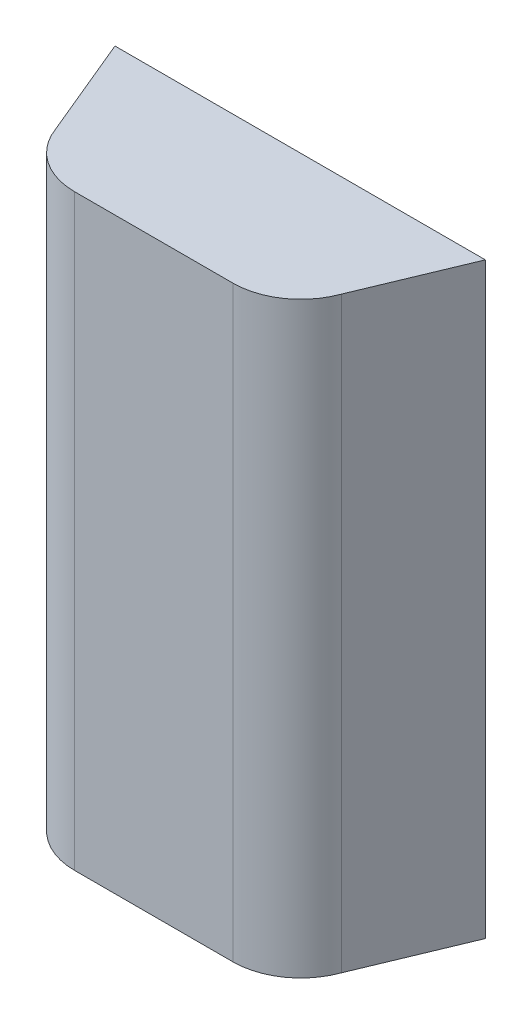
from build123d import *

# Parameters (mm, degrees)
BOSS_EXTRUDE1_DEPTH = 260
CUT_EXTRUDE1_DEPTH  = 256


with BuildPart() as part:
    # Sketch1 → Boss-Extrude1 (new body)
    with BuildSketch(Plane(origin=(0, 0, 0), x_dir=(1, 0, 0), z_dir=(0, 1, 0))):
        with BuildLine():
            Line((35, 0), (-35, 0))
            ThreePointArc((-35, 0), (-52.207293091, 5.425438671), (-63.190778624, 19.7393957))
            Line((-63.190778624, 19.7393957), (-81.908713693, 64.7393957))
            Line((-81.908713693, 64.7393957), (81.908713693, 64.7393957))
            Line((81.908713693, 64.7393957), (63.190778624, 19.7393957))
            ThreePointArc((63.190778624, 19.7393957), (52.207293091, 5.425438671), (35, 0))
        make_face()
    extrude(amount=BOSS_EXTRUDE1_DEPTH)

    # Sketch4 → Cut-Extrude1 (cut)
    with BuildSketch(Plane.XZ):
        with BuildLine():
            Line((-78.908713693, -64.7393957), (78.908713693, -64.7393957))
            Line((78.908713693, -64.7393957), (60.788869437, -21.764400459))
            add(Edge.make_bspline(
                [(35, -3), (54.769523096, -6.842262635), (60.788869437, -21.764400459)],
                knots=[0, 0, 0, 1, 1, 1], degree=2))
            Line((35, -3), (-35, -3))
            add(Edge.make_bspline(
                [(-35, -3), (-54.769523096, -6.842262635), (-60.788869437, -21.764400459)],
                knots=[0, 0, 0, 1, 1, 1], degree=2))
            Line((-60.788869437, -21.764400459), (-78.908713693, -64.7393957))
        make_face()
    extrude(amount=-CUT_EXTRUDE1_DEPTH, mode=Mode.SUBTRACT)


solid = part.part
